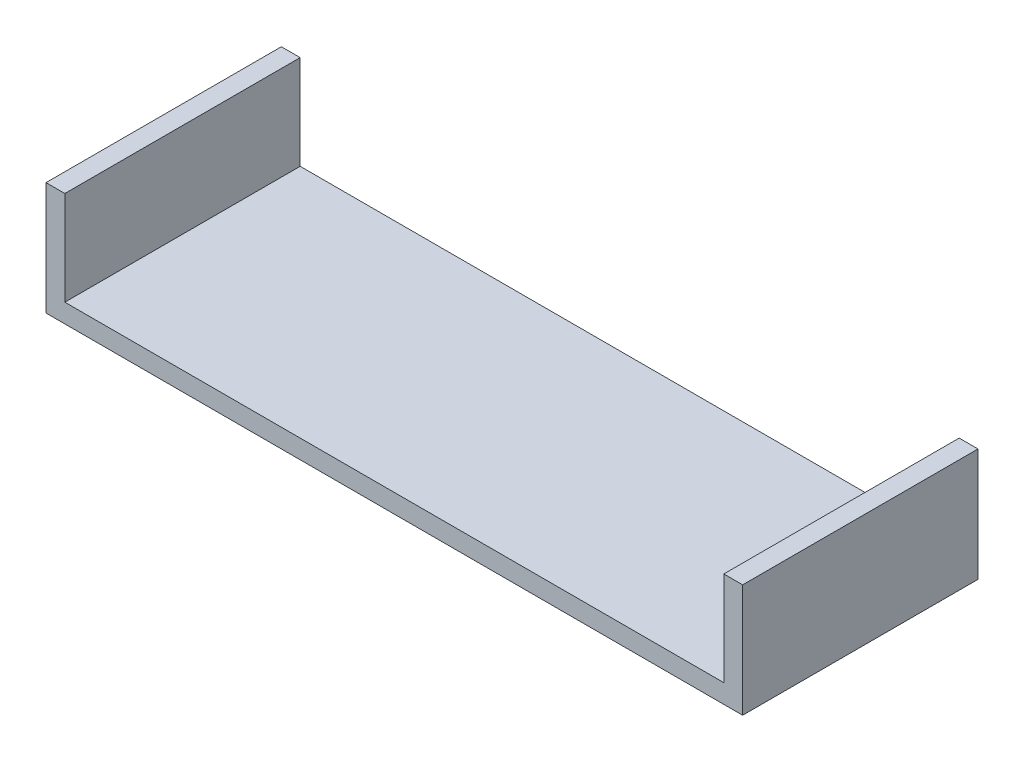
from build123d import *

# Parameters (mm, degrees)
BOSS_EXTRUDE1_DEPTH = 317.5


with BuildPart() as part:
    # Sketch1 → Boss-Extrude1 (new, symmetric)
    with BuildSketch(Plane.XY):
        Polygon((-939.8, 0), (939.8, 0), (939.8, 304.8), (889, 304.8), (889, 50.8), (-889, 50.8), (-889, 304.8), (-939.8, 304.8), align=None)
    extrude(amount=BOSS_EXTRUDE1_DEPTH, both=True)


solid = part.part
